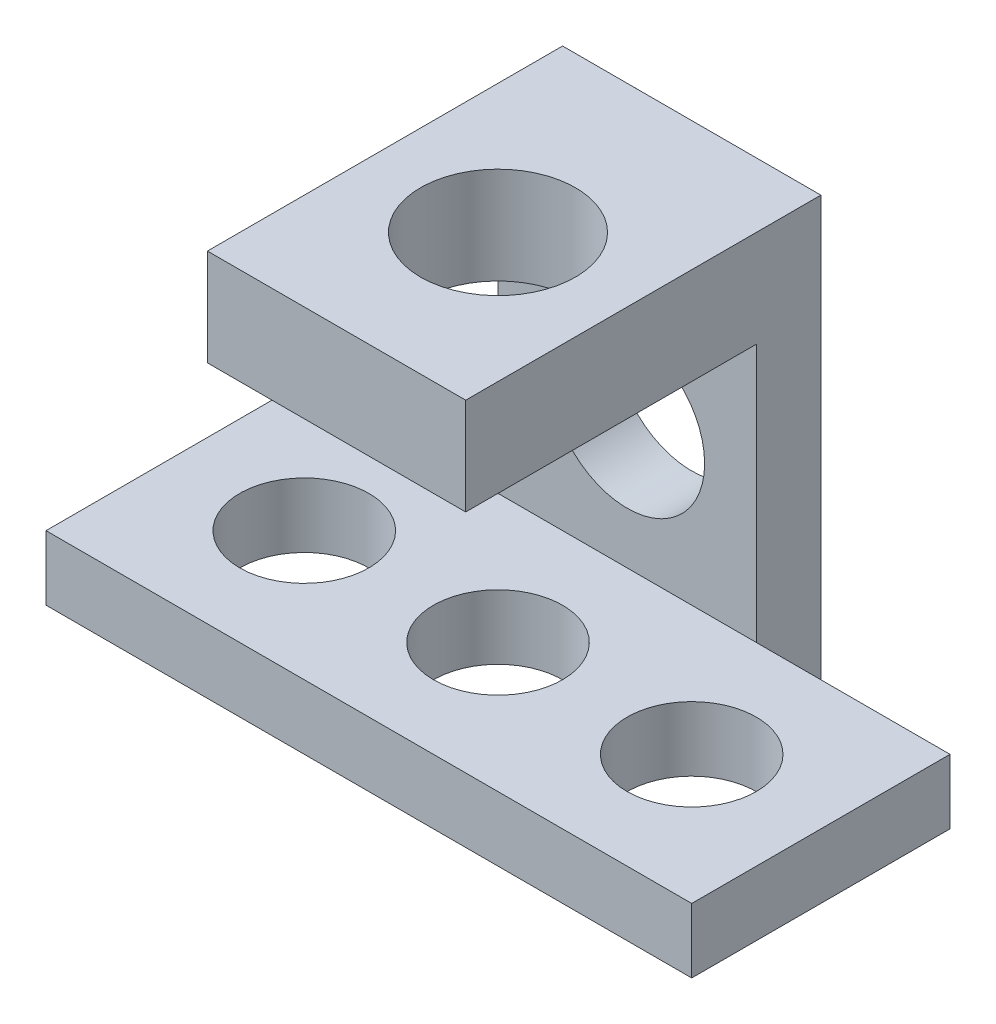
from build123d import *

# Parameters (mm, degrees)
BOSS_EXTRUDE1_DEPTH = 10
SKETCH3_R           = 10
CUT_EXTRUDE1_DEPTH  = 10
SKETCH4_W           = 40
SKETCH4_H           = 10
BOSS_EXTRUDE3_DEPTH = 55
SKETCH6_R           = 12
CUT_EXTRUDE2_DEPTH  = 10
SKETCH7_W           = 40
SKETCH7_H           = 15
BOSS_EXTRUDE4_DEPTH = 45
SKETCH8_R           = 12
CUT_EXTRUDE3_DEPTH  = 15


with BuildPart() as part:
    # Sketch2 → Boss-Extrude1 (new body)
    with BuildSketch(Plane(origin=(0, 0, 0), x_dir=(1, 0, 0), z_dir=(0, 1, 0))):
        Polygon((0, 0), (100, 0), (100, 40), (70, 40), (70, 50), (30, 50), (30, 40), (0, 40), align=None)
    extrude(amount=BOSS_EXTRUDE1_DEPTH)

    # Sketch3 → Cut-Extrude1 (cut)
    with BuildSketch(Plane(origin=(0, 10, 0), x_dir=(1, 0, 0), z_dir=(0, 1, 0))):
        with Locations((80, 20)):
            Circle(SKETCH3_R)
        with Locations((50, 20)):
            Circle(SKETCH3_R)
        with Locations((20, 20)):
            Circle(SKETCH3_R)
    extrude(amount=-CUT_EXTRUDE1_DEPTH, mode=Mode.SUBTRACT)

    # Sketch4 → Boss-Extrude3 (add)
    with BuildSketch(Plane(origin=(0, 10, 0), x_dir=(1, 0, 0), z_dir=(0, 1, 0))):
        with Locations((50, 45)):
            Rectangle(SKETCH4_W, SKETCH4_H)
    extrude(amount=BOSS_EXTRUDE3_DEPTH)

    # Sketch6 → Cut-Extrude2 (cut)
    with BuildSketch(Plane.XY.offset(-40)):
        with Locations((50, 30)):
            Circle(SKETCH6_R)
    extrude(amount=-CUT_EXTRUDE2_DEPTH, mode=Mode.SUBTRACT)

    # Sketch7 → Boss-Extrude4 (add)
    with BuildSketch(Plane.XY.offset(-40)):
        with Locations((50, 57.5)):
            Rectangle(SKETCH7_W, SKETCH7_H)
    extrude(amount=BOSS_EXTRUDE4_DEPTH)

    # Sketch8 → Cut-Extrude3 (cut)
    with BuildSketch(Plane(origin=(0, 65, 0), x_dir=(1, 0, 0), z_dir=(0, 1, 0))):
        with Locations((50, 20)):
            Circle(SKETCH8_R)
    extrude(amount=-CUT_EXTRUDE3_DEPTH, mode=Mode.SUBTRACT)


solid = part.part
